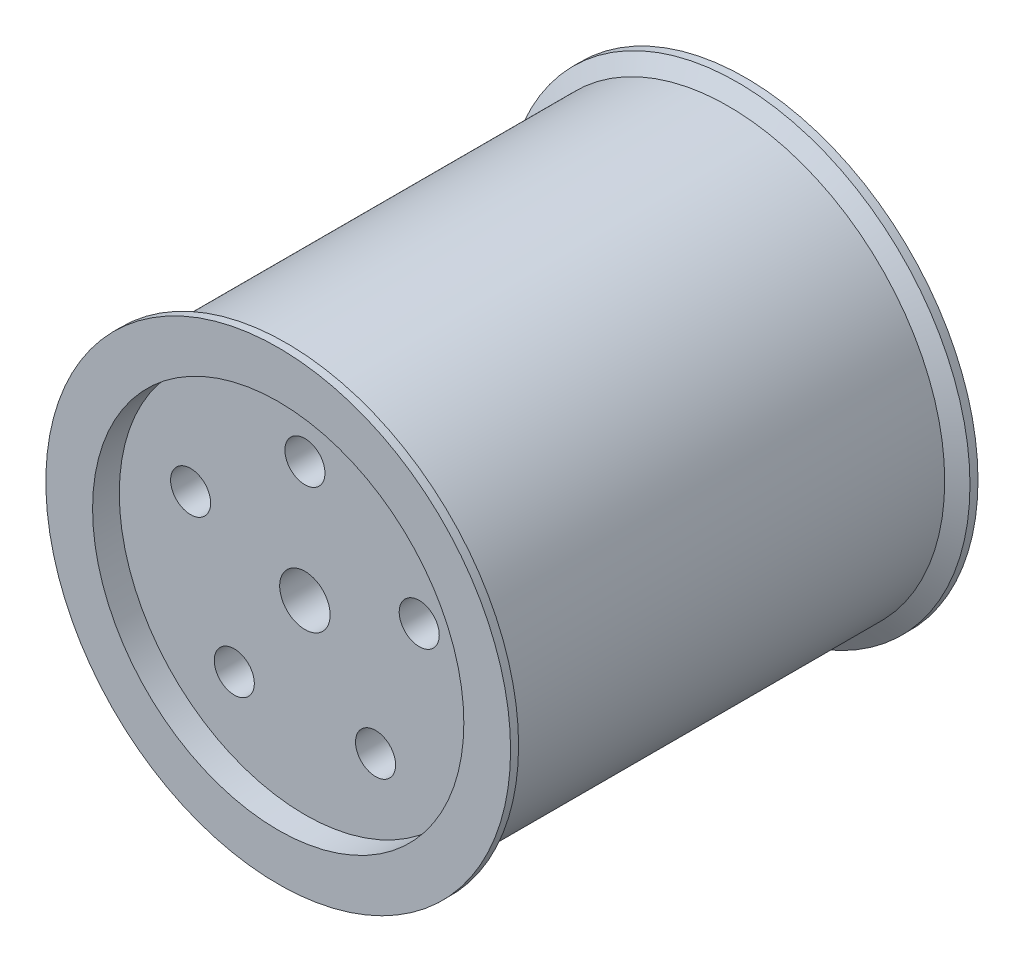
from build123d import *

# Parameters (mm, degrees)
SKETCH1_R               = 87
BOSS_EXTRUDE1_DEPTH     = 87.5
SKETCH2_R               = 9.4488
CUT_EXTRUDE1_DEPTH      = 1
CUT_EXTRUDE1_DEPTH_BACK = 176
SKETCH3_R               = 69.5
CUT_EXTRUDE2_DEPTH      = 10
SKETCH7_R               = 7.5
CUT_EXTRUDE3_DEPTH      = 166
CIRPATTERN1_COUNT       = 5


with BuildPart() as part:
    # Sketch1 → Boss-Extrude1 (new body, symmetric)
    with BuildSketch(Plane.XY):
        Circle(SKETCH1_R)
    extrude(amount=BOSS_EXTRUDE1_DEPTH, both=True)

    # Sketch2 → Cut-Extrude1 (cut, two sides)
    with BuildSketch(Plane.XY.offset(87.5)) as cut_extrude1_sk:
        Circle(SKETCH2_R)
    extrude(amount=CUT_EXTRUDE1_DEPTH, mode=Mode.SUBTRACT)
    extrude(cut_extrude1_sk.sketch, amount=-CUT_EXTRUDE1_DEPTH_BACK, mode=Mode.SUBTRACT)

    # Sketch3 → Cut-Extrude2 (cut)
    with BuildSketch(Plane.XY.offset(87.5)):
        Circle(SKETCH3_R)
    cut_extrude2 = extrude(amount=-CUT_EXTRUDE2_DEPTH, mode=Mode.SUBTRACT)

    # Mirror1: Cut-Extrude2 across plane
    add(cut_extrude2.mirror(Plane.XY), mode=Mode.SUBTRACT)

    # Sketch5 → Cut-Revolve1 (revolve, cut)
    with BuildSketch(Plane(origin=(0, 0, 0), x_dir=(1, 0, 0), z_dir=(0, 1, 0))):
        Polygon((87, 84.5), (81, 81.035898385), (81, -81.035898385), (87, -84.5), align=None)
    revolve(axis=Axis((0, 0, 0), (0, 0, -1)), mode=Mode.SUBTRACT)

    # Sketch7 → Cut-Extrude3 (cut, through all)
    with BuildSketch(Plane.XY.offset(77.5)):
        with Locations((0, 45)):
            Circle(SKETCH7_R)
    cut_extrude3 = extrude(amount=-CUT_EXTRUDE3_DEPTH, mode=Mode.SUBTRACT)

    # CirPattern1: Cut-Extrude3 ×5 about axis
    cirpattern1_axis = Axis((0, 0, 0), (0, 0, 1))
    for i in range(1, CIRPATTERN1_COUNT):
        add(cut_extrude3.rotate(cirpattern1_axis, i * 360 / CIRPATTERN1_COUNT), mode=Mode.SUBTRACT)


solid = part.part
